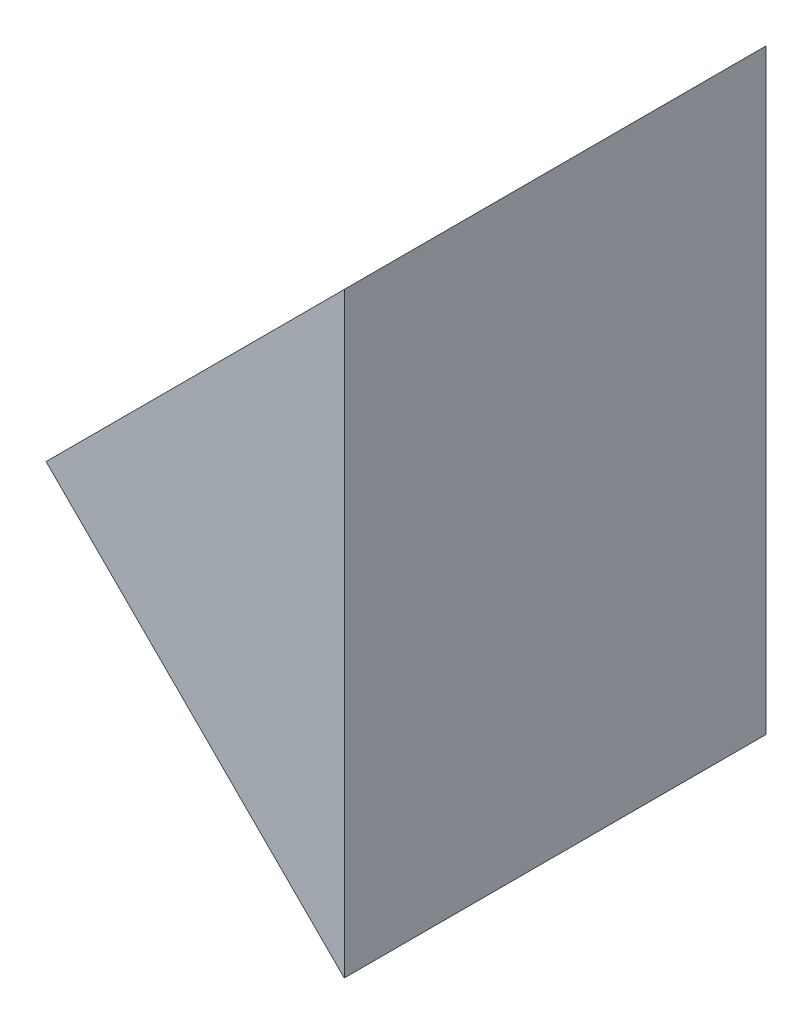
from build123d import *

# Parameters (mm, degrees)
EXTRUDE_1_DEPTH = 30


with BuildPart() as part:
    # 草图1 → 凸台-拉伸1 (new body)
    with BuildSketch(Plane.XY):
        Polygon((295.061019293, 90.091665945), (273.847815857, 68.878462509), (295.061019293, 47.665259074), align=None)
    extrude(amount=EXTRUDE_1_DEPTH)


solid = part.part
